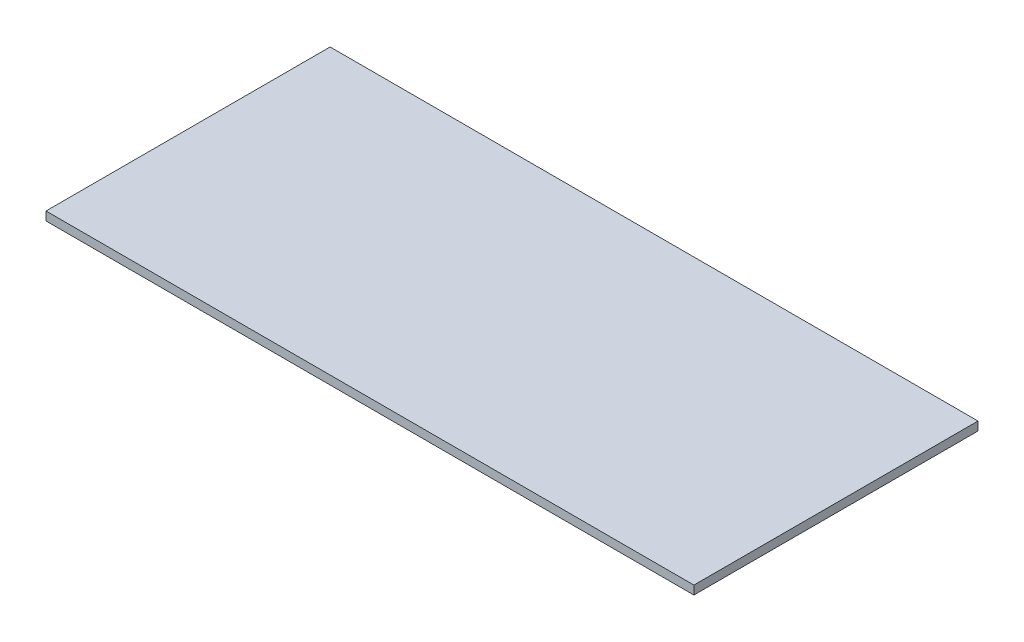
from build123d import *

# Parameters (mm, degrees)
SKETCH1_W           = 118.745
SKETCH1_H           = 52.07
BOSS_EXTRUDE1_DEPTH = 1.5875


with BuildPart() as part:
    # Sketch1 → Boss-Extrude1 (new body)
    with BuildSketch(Plane(origin=(0, 0, 0), x_dir=(1, 0, 0), z_dir=(0, 1, 0))):
        with Locations((59.3725, 26.035)):
            Rectangle(SKETCH1_W, SKETCH1_H)
    extrude(amount=BOSS_EXTRUDE1_DEPTH)


solid = part.part
